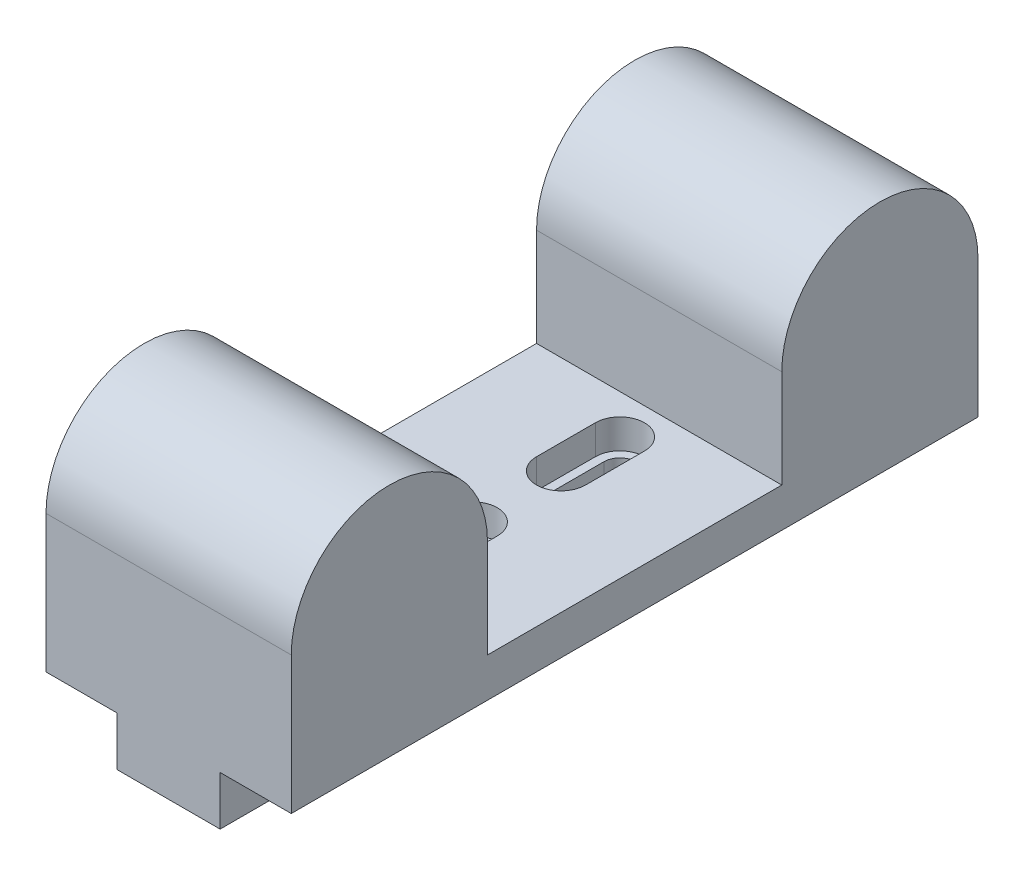
from build123d import *

# Parameters (mm, degrees)
BOSS_EXTRUDE1_DEPTH     = 12.5
SKETCH2_W               = 10.5
SKETCH2_H               = 41.75
BOSS_EXTRUDE2_DEPTH     = 5
CUT_EXTRUDE1_DEPTH      = 25
CUT_EXTRUDE1_DEPTH_BACK = 6
CUT_EXTRUDE2_START      = 4
CUT_EXTRUDE2_DEPTH      = 3


with BuildPart() as part:
    # Sketch1 → Boss-Extrude1 (new body, symmetric)
    with BuildSketch(Plane(origin=(0, 0, 0), x_dir=(0, 0, -1), z_dir=(1, 0, 0))):
        with BuildLine():
            Line((0, 0), (70, 0))
            Line((70, 0), (70, 14))
            ThreePointArc((70, 14), (60, 24), (50, 14))
            Line((50, 14), (50, 4))
            Line((50, 4), (20, 4))
            Line((20, 4), (20, 14))
            ThreePointArc((20, 14), (10, 24), (0, 14))
            Line((0, 14), (0, 0))
        make_face()
    extrude(amount=BOSS_EXTRUDE1_DEPTH, both=True)

    # Sketch2 → Boss-Extrude2 (add)
    with BuildSketch(Plane(origin=(0, 0, 0), x_dir=(1, 0, 0), z_dir=(0, 1, 0))):
        with BuildLine():
            ThreePointArc((-5.25, 41.75), (0, 47), (5.25, 41.75))
            Line((5.25, 41.75), (-5.25, 41.75))
        make_face()
        with Locations((0, 20.875)):
            Rectangle(SKETCH2_W, SKETCH2_H)
    extrude(amount=-BOSS_EXTRUDE2_DEPTH)

    # Sketch4 → Cut-Extrude1 (cut, two sides)
    with BuildSketch(Plane(origin=(0, 0, 0), x_dir=(1, 0, 0), z_dir=(0, 1, 0))) as cut_extrude1_sk:
        with BuildLine():
            Line((1.625, 31), (1.625, 25))
            ThreePointArc((1.625, 25), (0, 23.375), (-1.625, 25))
            Line((-1.625, 25), (-1.625, 31))
            ThreePointArc((-1.625, 31), (0, 32.625), (1.625, 31))
        make_face()
        with BuildLine():
            Line((1.625, 46), (1.625, 40))
            ThreePointArc((1.625, 40), (0, 38.375), (-1.625, 40))
            Line((-1.625, 40), (-1.625, 46))
            ThreePointArc((-1.625, 46), (0, 47.625), (1.625, 46))
        make_face()
    extrude(amount=CUT_EXTRUDE1_DEPTH, mode=Mode.SUBTRACT)
    extrude(cut_extrude1_sk.sketch, amount=-CUT_EXTRUDE1_DEPTH_BACK, mode=Mode.SUBTRACT)

    # Sketch4_3 → Cut-Extrude2 (cut)
    with BuildSketch(Plane(origin=(0, 0, 0), x_dir=(1, 0, 0), z_dir=(0, 1, 0)).offset(CUT_EXTRUDE2_START)):
        with BuildLine():
            Line((-2.5, 31), (-2.5, 25))
            ThreePointArc((-2.5, 25), (0, 22.5), (2.5, 25))
            Line((2.5, 25), (2.5, 31))
            ThreePointArc((2.5, 31), (0, 33.5), (-2.5, 31))
        make_face()
        with BuildLine():
            ThreePointArc((1.625, 31), (0, 32.625), (-1.625, 31))
            Line((-1.625, 31), (-1.625, 25))
            ThreePointArc((-1.625, 25), (0, 23.375), (1.625, 25))
            Line((1.625, 25), (1.625, 31))
        make_face(mode=Mode.SUBTRACT)
        with BuildLine():
            Line((-2.5, 46), (-2.5, 40))
            ThreePointArc((-2.5, 40), (0, 37.5), (2.5, 40))
            Line((2.5, 40), (2.5, 46))
            ThreePointArc((2.5, 46), (0, 48.5), (-2.5, 46))
        make_face()
        with BuildLine():
            ThreePointArc((1.625, 46), (0, 47.625), (-1.625, 46))
            Line((-1.625, 46), (-1.625, 40))
            ThreePointArc((-1.625, 40), (0, 38.375), (1.625, 40))
            Line((1.625, 40), (1.625, 46))
        make_face(mode=Mode.SUBTRACT)
    extrude(amount=-CUT_EXTRUDE2_DEPTH, mode=Mode.SUBTRACT)


solid = part.part
